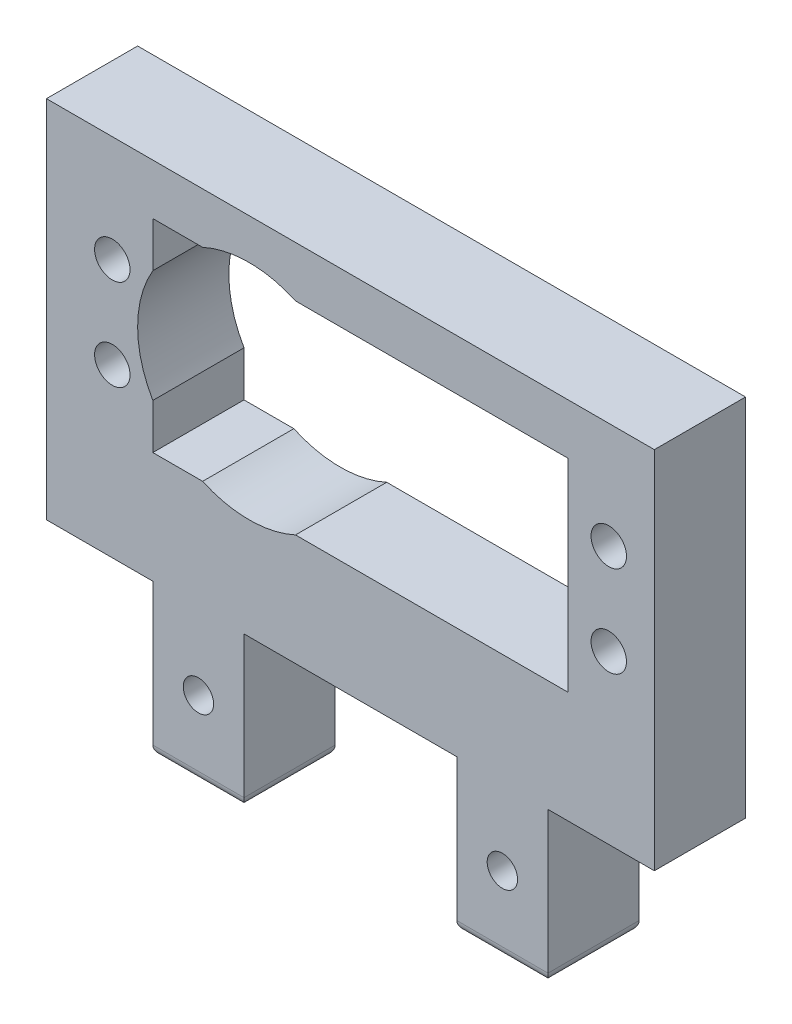
from build123d import *

# Parameters (mm, degrees)
CROQUIS1_R              = 1.75
CROQUIS1_R_2            = 1.5
SALIENTE_EXTRUIR1_DEPTH = 9
REDONDEO1_R             = 1


with BuildPart() as part:
    # Croquis1 → Saliente-Extruir1 (new body)
    with BuildSketch(Plane.XY):
        Polygon((0, 36), (0, 0), (10.5, 0), (10.5, -15), (19.5, -15), (19.5, 0), (40.5, 0), (40.5, -15), (49.5, -15), (49.5, 0), (60, 0), (60, 36), align=None)
        with Locations((6.5, 16.5)):
            Circle(CROQUIS1_R, mode=Mode.SUBTRACT)
        with Locations((6.5, 25.5)):
            Circle(CROQUIS1_R, mode=Mode.SUBTRACT)
        with BuildLine():
            Line((10.5, 26.545268253), (10.5, 31))
            Line((10.5, 31), (15.417424305, 31))
            ThreePointArc((15.417424305, 31), (20, 32), (24.582575695, 31))
            Line((24.582575695, 31), (51.5, 31))
            Line((51.5, 31), (51.5, 11))
            Line((51.5, 11), (24.582575695, 11))
            ThreePointArc((24.582575695, 11), (20, 10), (15.417424305, 11))
            Line((15.417424305, 11), (10.5, 11))
            Line((10.5, 11), (10.5, 15.454731747))
            ThreePointArc((10.5, 15.454731747), (9, 21), (10.5, 26.545268253))
        make_face(mode=Mode.SUBTRACT)
        with Locations((55.5, 16.5)):
            Circle(CROQUIS1_R, mode=Mode.SUBTRACT)
        with Locations((55.5, 25.5)):
            Circle(CROQUIS1_R, mode=Mode.SUBTRACT)
        with Locations((15, -7.5)):
            Circle(CROQUIS1_R_2, mode=Mode.SUBTRACT)
        with Locations((45, -7.5)):
            Circle(CROQUIS1_R_2, mode=Mode.SUBTRACT)
    extrude(amount=SALIENTE_EXTRUIR1_DEPTH)

    # Redondeo1
    redondeo1_edges = [part.edges().sort_by_distance(p)[0] for p in [
        (45, -15, 0),
        (15, -15, 0),
        (49.5, -15, 4.5),
        (40.5, -15, 4.5),
        (19.5, -15, 4.5),
        (10.5, -15, 4.5),
        (15, -15, 9),
        (45, -15, 9),
    ]]
    fillet(redondeo1_edges, radius=REDONDEO1_R)


solid = part.part
